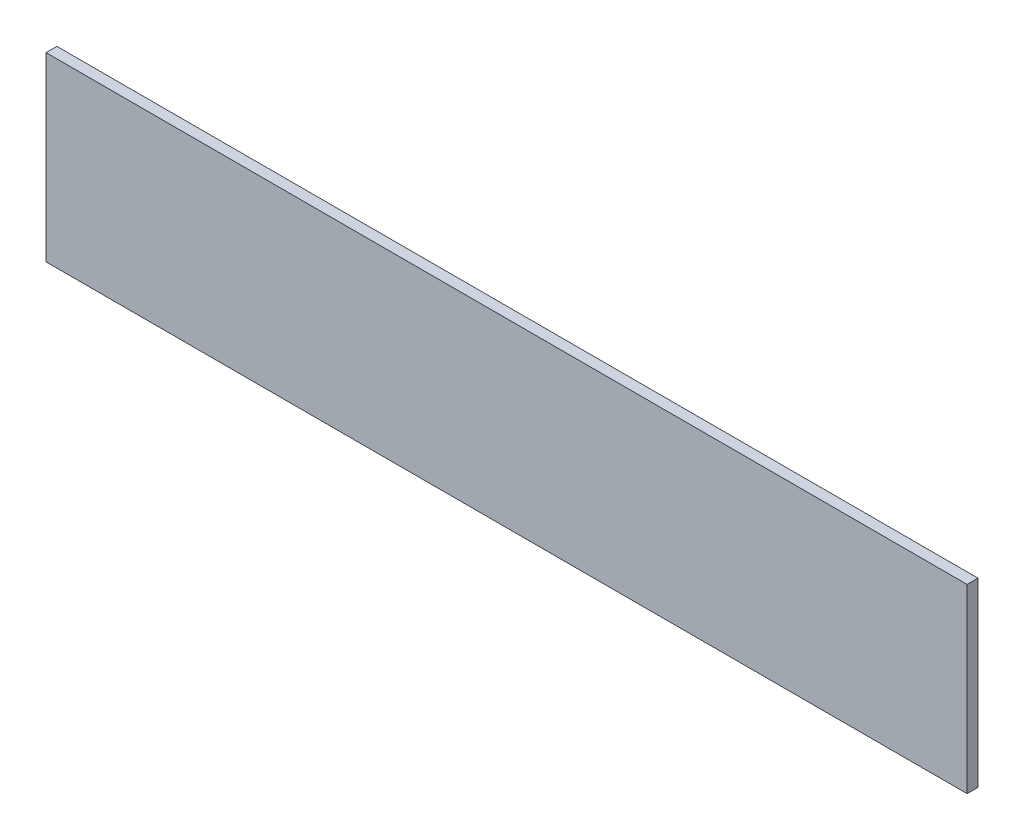
from build123d import *

# Parameters (mm, degrees)
SKIZZE1_W                       = 1525
SKIZZE1_H                       = 300
AUFSATZ_LINEAR_AUSTRAGEN1_DEPTH = 18


with BuildPart() as part:
    # Skizze1 → Aufsatz-Linear austragen1 (new body)
    with BuildSketch(Plane.XY):
        Rectangle(SKIZZE1_W, SKIZZE1_H)
    extrude(amount=AUFSATZ_LINEAR_AUSTRAGEN1_DEPTH)


solid = part.part
